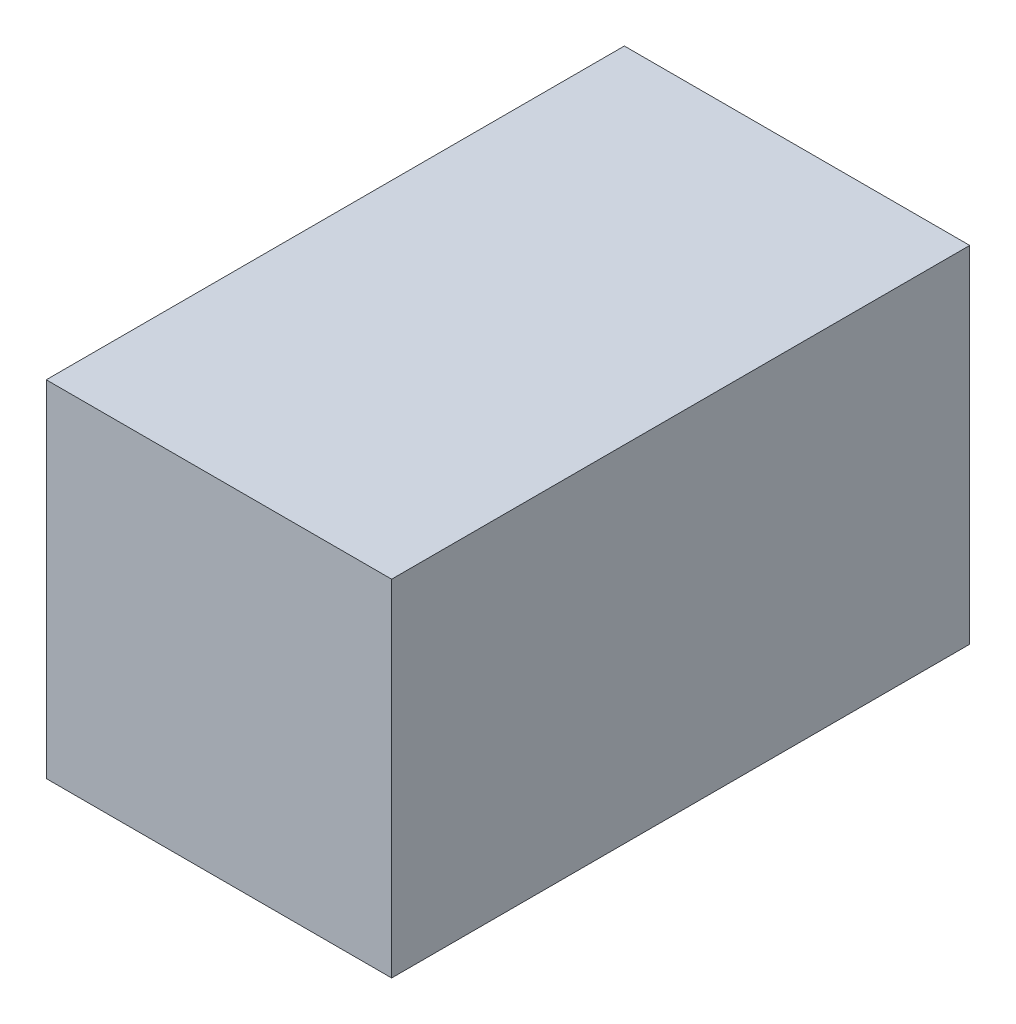
from build123d import *

# Parameters (mm, degrees)
SKETCH1_W                = 44.45
SKETCH1_H                = 44.45
BOSS_EXTRUDE1_DEPTH      = 35
BOSS_EXTRUDE1_DEPTH_BACK = 39.4


with BuildPart() as part:
    # Sketch1 → Boss-Extrude1 (new body, two sides)
    with BuildSketch(Plane.XY) as boss_extrude1_sk:
        Rectangle(SKETCH1_W, SKETCH1_H)
    extrude(amount=BOSS_EXTRUDE1_DEPTH)
    extrude(boss_extrude1_sk.sketch, amount=-BOSS_EXTRUDE1_DEPTH_BACK)


solid = part.part
